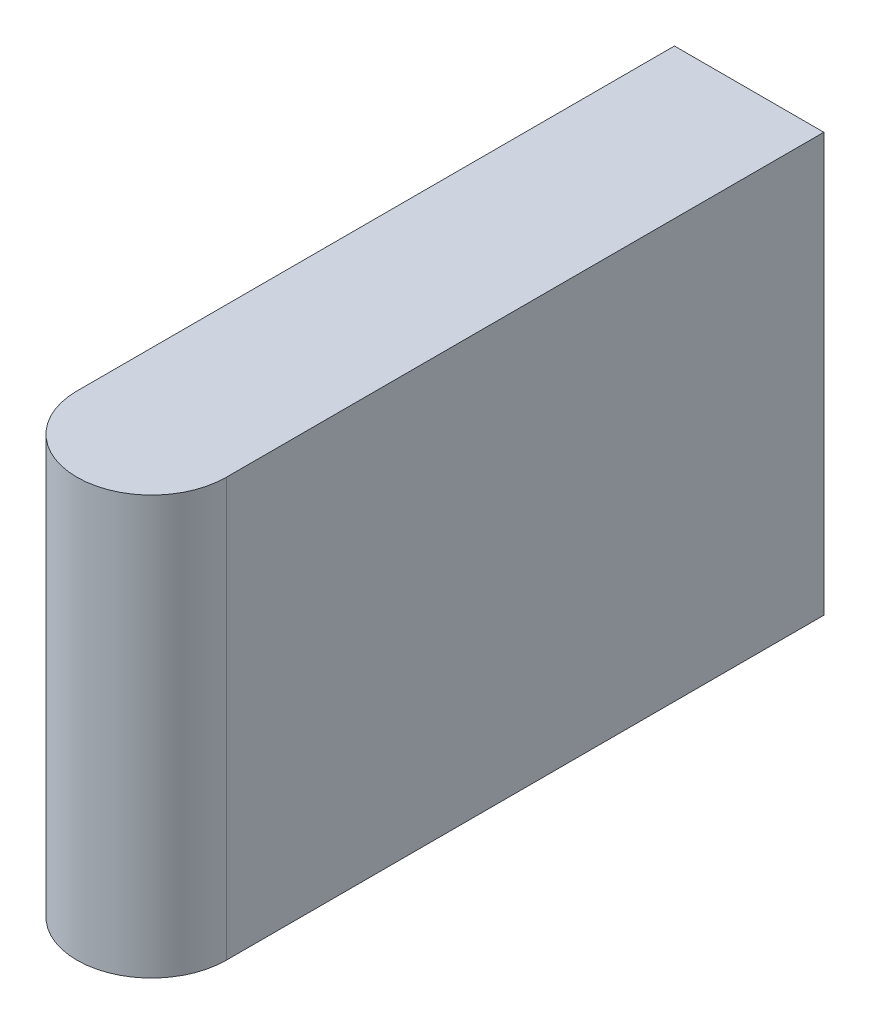
from build123d import *

# Parameters (mm, degrees)
BASE_EXTRUSION_DEPTH = 1.4


with BuildPart() as part:
    # Esquisse1 → Base-Extrusion (new body, symmetric)
    with BuildSketch(Plane(origin=(0, 0, 0), x_dir=(1, 0, 0), z_dir=(0, 1, 0))):
        with BuildLine():
            Line((0.5, 0), (0.5, -4))
            ThreePointArc((0.5, -4), (0, -4.5), (-0.5, -4))
            Line((-0.5, -4), (-0.5, 0))
            Line((-0.5, 0), (0.5, 0))
        make_face()
    extrude(amount=BASE_EXTRUSION_DEPTH, both=True)


solid = part.part
